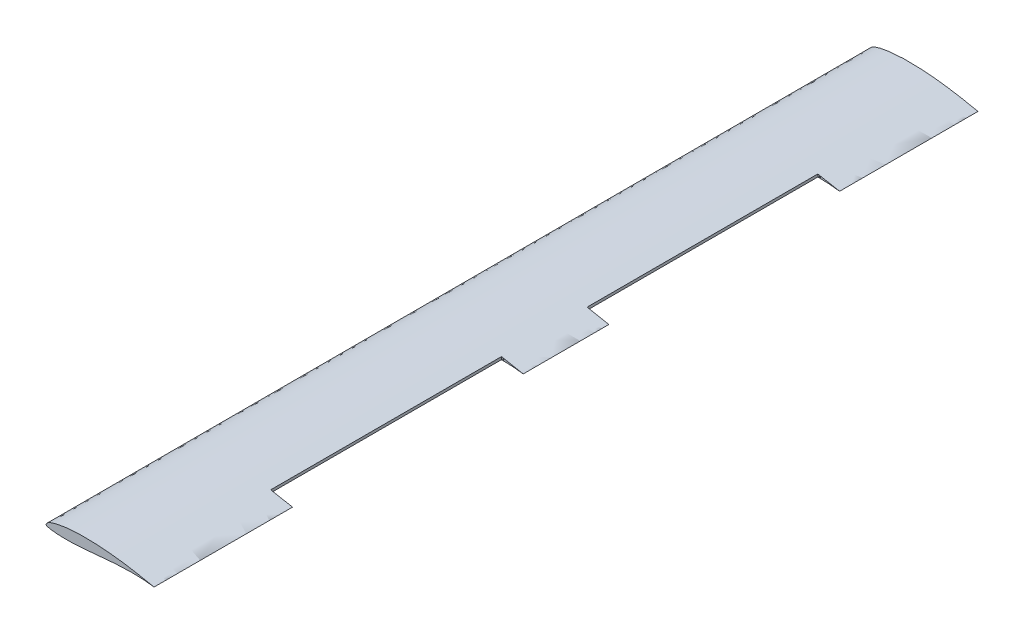
from build123d import *

# Parameters (mm, degrees)
WING_SPAN_DEPTH         = 1250
FLAP_SPACE_DEPTH        = 110
FLAP_SPACE_DEPTH_BACK   = 246
SKETCH4_W               = 33
SKETCH4_H               = 350
CUT_EXTRUDE3_DEPTH      = 370
CUT_EXTRUDE3_DEPTH_BACK = 29
SKETCH5_R               = 1
CUT_EXTRUDE4_DEPTH      = 366
CUT_EXTRUDE4_DEPTH_BACK = 22
SKETCH6_R               = 0.999999993


with BuildPart() as part:
    # Sketch2 → Wing span (new body)
    with BuildSketch(Plane.XY):
        with BuildLine():
            add(Edge.make_bspline(
                [(164, 0), (164.001991598, 0.00531985), (162.498434343, 0.297400203), (160.966285987, 0.616919952), (157.230075916, 1.35854981), (152.647727614, 2.276655229), (146.674778271, 3.452593401), (139.663921431, 4.788107638), (131.643002502, 6.225523454), (122.779722168, 7.678120549), (113.214717928, 9.062609537), (103.114761216, 10.30867808), (92.653330955, 11.366874663), (82.008680624, 12.183570909), (71.363717138, 12.732678494), (62.573062305, 12.938820128), (55.679219616, 12.931629583), (50.66379262, 12.839728664), (45.782181562, 12.659463205), (41.055239208, 12.3903785), (36.503682969, 12.036437473), (32.146930875, 11.601780671), (28.004239994, 11.085142861), (24.091702865, 10.49834901), (20.426822474, 9.843918183), (17.025844132, 9.130833564), (13.902230709, 8.369358841), (11.06833563, 7.565562996), (8.53577437, 6.720118621), (6.312379055, 5.832916092), (4.413351959, 4.89013994), (2.84511205, 3.903245047), (1.620457598, 2.901127061), (0.731165093, 1.938080692), (0.179493112, 1.068674431), (-0.069462085, 0.284825746), (0.1340338, -0.423690631), (0.764071957, -0.903152486), (1.66761423, -1.285012606), (2.89636931, -1.667860408), (4.454368995, -2.060754755), (6.342184668, -2.463268111), (8.554678564, -2.849189029), (11.082153575, -3.197036089), (13.91354845, -3.489623602), (17.035473755, -3.733426896), (20.435651878, -3.919184892), (24.099392464, -4.054926113), (28.010855137, -4.127538534), (32.152921407, -4.140988099), (36.508800602, -4.082499209), (41.059834749, -3.949191021), (45.786267855, -3.736710609), (50.667246714, -3.44561856), (55.681487768, -3.077952812), (62.575429044, -2.5099648), (71.360013547, -1.687848394), (81.99774075, -0.654631351), (92.636555888, 0.330119403), (103.095163283, 1.174218069), (113.195150773, 1.80138175), (122.763237889, 2.175762051), (131.632477935, 2.284101672), (139.659679629, 2.147275472), (146.676584213, 1.826335034), (152.651459073, 1.377599866), (157.237589271, 0.924994424), (160.965141957, 0.442021742), (162.505368274, 0.239871333), (163.998025246, -0.005274856), (164, 0)],
                knots=[0, 0, 0, 0, 0.002148054, 0.008549751, 0.019093203, 0.033601904, 0.051811667, 0.073403086, 0.097969443, 0.125069858, 0.154220145, 0.184909694, 0.216620256, 0.248810746, 0.280948927, 0.312507484, 0.327906501, 0.342968756, 0.35763527, 0.371852485, 0.385561874, 0.398705235, 0.41124018, 0.423117643, 0.434295112, 0.444729135, 0.454375798, 0.463214982, 0.47122318, 0.478387129, 0.484734913, 0.490272765, 0.495019578, 0.498937389, 0.50200172, 0.504262281, 0.506099972, 0.508217729, 0.511109021, 0.514949183, 0.519768397, 0.525567786, 0.532308947, 0.539970427, 0.548516152, 0.557914396, 0.568140585, 0.579150255, 0.590897187, 0.603335474, 0.616414202, 0.630087791, 0.644295999, 0.65897818, 0.674077354, 0.689528147, 0.721210905, 0.753454187, 0.785684185, 0.817334233, 0.847849866, 0.876721279, 0.903468398, 0.927655074, 0.948890459, 0.966808427, 0.981110174, 0.991529529, 0.997870113, 1, 1, 1, 1], degree=3))
        make_face()
    extrude(amount=WING_SPAN_DEPTH)

    # Sketch4 → Flap space (cut, two sides: drawn at the far end of the back side and taken through both)
    with BuildSketch(Plane(origin=(0, 0, 0), x_dir=(1, 0, 0), z_dir=(0, 1, 0)).offset(-FLAP_SPACE_DEPTH_BACK)):
        with Locations((147.500007842, -865)):
            Rectangle(SKETCH4_W, SKETCH4_H)
        with Locations((147.500007842, -385)):
            Rectangle(SKETCH4_W, SKETCH4_H)
    extrude(amount=FLAP_SPACE_DEPTH + FLAP_SPACE_DEPTH_BACK, mode=Mode.SUBTRACT)

    # Sketch5 → Cut-Extrude3 (cut, two sides: drawn at the far end of the back side and taken through both)
    with BuildSketch(Plane(origin=(0, 0, 560), x_dir=(-1, 0, 0), z_dir=(0, 0, -1)).offset(-CUT_EXTRUDE3_DEPTH_BACK)):
        with Locations((-133.938891559, 3.676038377)):
            Circle(SKETCH5_R)
    extrude(amount=CUT_EXTRUDE3_DEPTH + CUT_EXTRUDE3_DEPTH_BACK, mode=Mode.SUBTRACT)

    # Sketch6 → Cut-Extrude4 (cut, two sides: drawn at the far end of the back side and taken through both)
    with BuildSketch(Plane(origin=(0, 0, 1040), x_dir=(-1, 0, 0), z_dir=(0, 0, -1)).offset(-CUT_EXTRUDE4_DEPTH_BACK)):
        with Locations(Location((-134.000007827, 4.247891524, 0), (0, 0, 180))):
            Circle(SKETCH6_R)
    extrude(amount=CUT_EXTRUDE4_DEPTH + CUT_EXTRUDE4_DEPTH_BACK, mode=Mode.SUBTRACT)


solid = part.part
